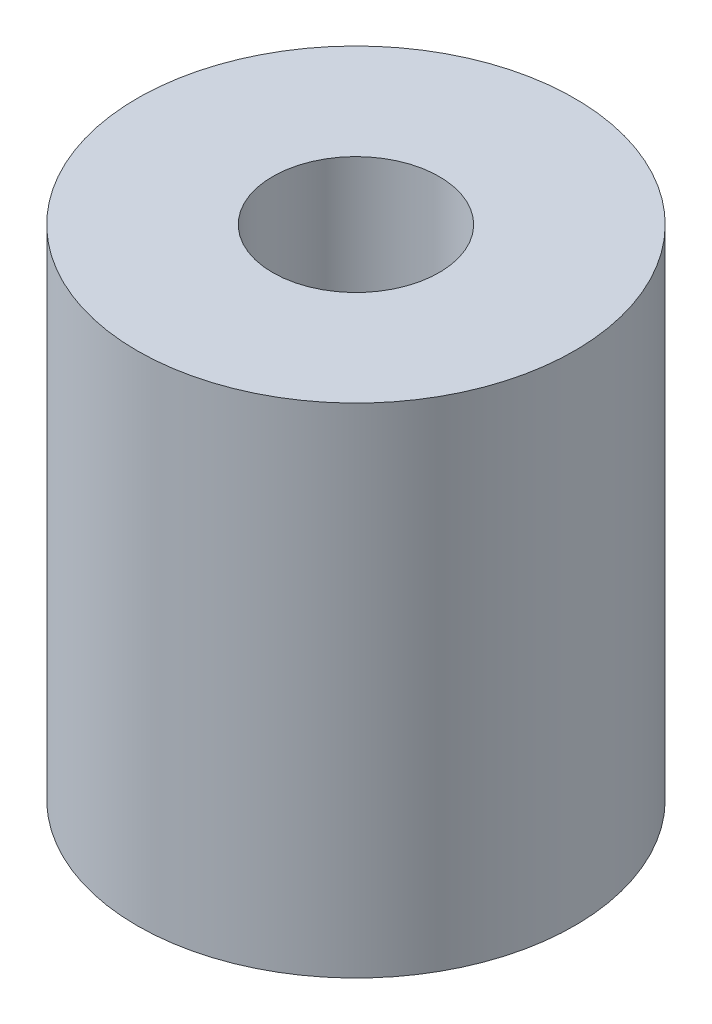
from build123d import *

# Parameters (mm, degrees)
SKETCH1_R           = 13
SKETCH1_R_2         = 4.95
BOSS_EXTRUDE1_DEPTH = 29.6
SKETCH2_R           = 4.95
BOSS_EXTRUDE3_DEPTH = 8.650573
SKETCH3_R           = 4.95
SKETCH3_R_2         = 3.9
BOSS_EXTRUDE4_DEPTH = 11.85


with BuildPart() as part:
    # Sketch1 → Boss-Extrude1 (new body)
    with BuildSketch(Plane(origin=(0, 0, 0), x_dir=(1, 0, 0), z_dir=(0, 1, 0))):
        Circle(SKETCH1_R)
        Circle(SKETCH1_R_2, mode=Mode.SUBTRACT)
    extrude(amount=BOSS_EXTRUDE1_DEPTH)

    # Sketch2 → Boss-Extrude3 (add)
    with BuildSketch(Plane(origin=(0, 18.650573, 0), x_dir=(1, 0, 0), z_dir=(0, 1, 0))):
        Circle(SKETCH2_R)
    extrude(amount=-BOSS_EXTRUDE3_DEPTH)

    # Sketch3 → Boss-Extrude4 (add)
    with BuildSketch(Plane.XZ):
        Circle(SKETCH3_R)
        Circle(SKETCH3_R_2, mode=Mode.SUBTRACT)
    extrude(amount=-BOSS_EXTRUDE4_DEPTH)


solid = part.part
